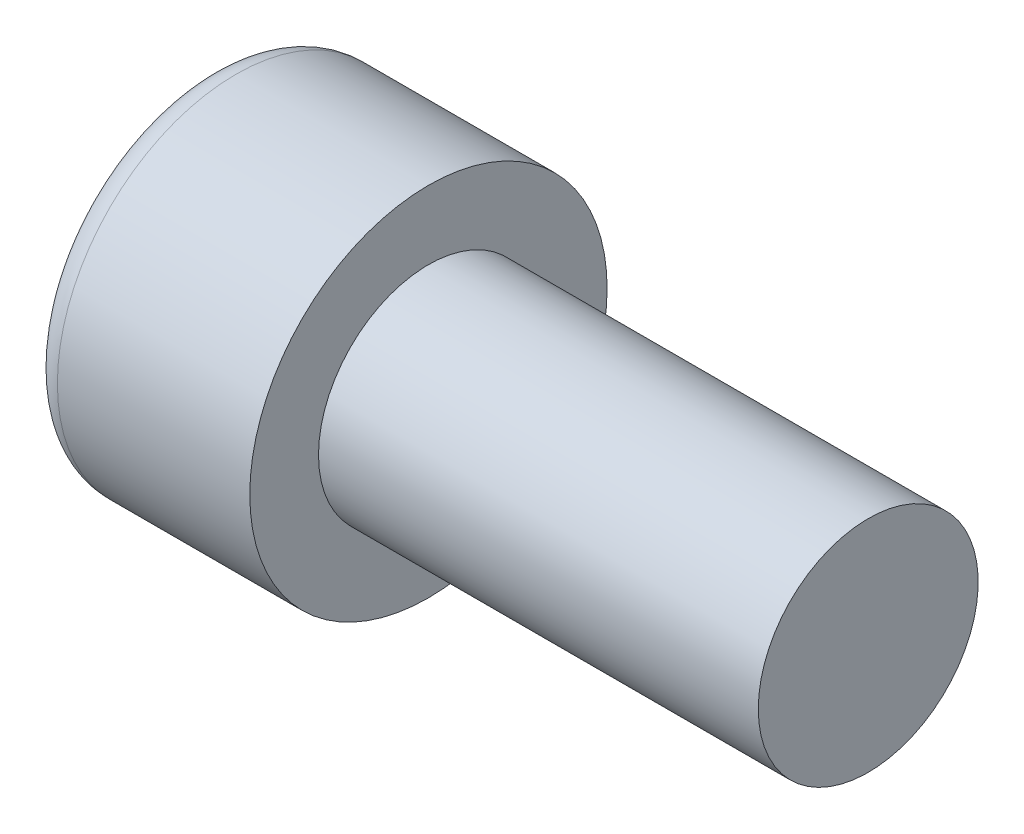
from build123d import *

# Parameters (mm, degrees)
CUT_EXTRUDE_1_DEPTH = 4
FILLET_1_R          = 1
FILLET_2_R          = 0.2


with BuildPart() as part:
    # Эскиз1 → Повернуть1 (revolve)
    with BuildSketch(Plane.XY):
        Polygon((-8, 0), (-8, 6.5), (0, 6.5), (0, 4), (16, 4), (16, 0), align=None)
    revolve(axis=Axis((-351.589582302, 0, 0), (1, 0, 0)))

    # Эскиз2 → Вырез-Вытянуть1 (cut)
    with BuildSketch(Plane.ZY.offset(8)):
        Polygon((0, -3.464101615), (3, -1.732050808), (3, 1.732050808), (0, 3.464101615), (-3, 1.732050808), (-3, -1.732050808), align=None)
    extrude(amount=-CUT_EXTRUDE_1_DEPTH, mode=Mode.SUBTRACT)

    # Скругление1
    fillet_1_edges = [part.edges().sort_by_distance(p)[0] for p in [
        (-8, -6.5, 0),
    ]]
    fillet(fillet_1_edges, radius=FILLET_1_R)

    # Скругление2
    fillet_2_edges = [part.edges().sort_by_distance(p)[0] for p in [
        (-8, -2.598076211, -1.5),
        (-8, -2.598076211, 1.5),
        (-8, 0, 3),
        (-8, 2.598076211, 1.5),
        (-8, 2.598076211, -1.5),
        (-8, 0, -3),
    ]]
    fillet(fillet_2_edges, radius=FILLET_2_R)


solid = part.part
